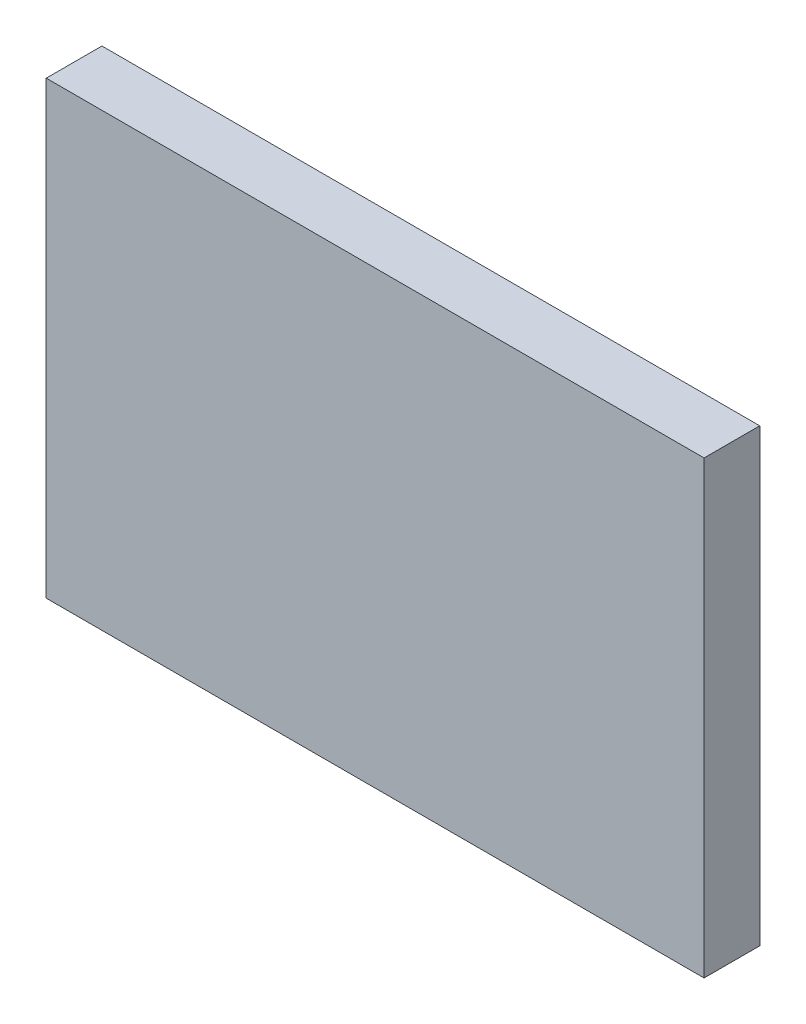
from build123d import *

# Parameters (mm, degrees)
SKETCH1_W           = 75
SKETCH1_H           = 51.35
BOSS_EXTRUDE1_DEPTH = 6.35


with BuildPart() as part:
    # Sketch1 → Boss-Extrude1 (new body)
    with BuildSketch(Plane.XY):
        with Locations((37.5, 25.675)):
            Rectangle(SKETCH1_W, SKETCH1_H)
    extrude(amount=BOSS_EXTRUDE1_DEPTH)


solid = part.part
